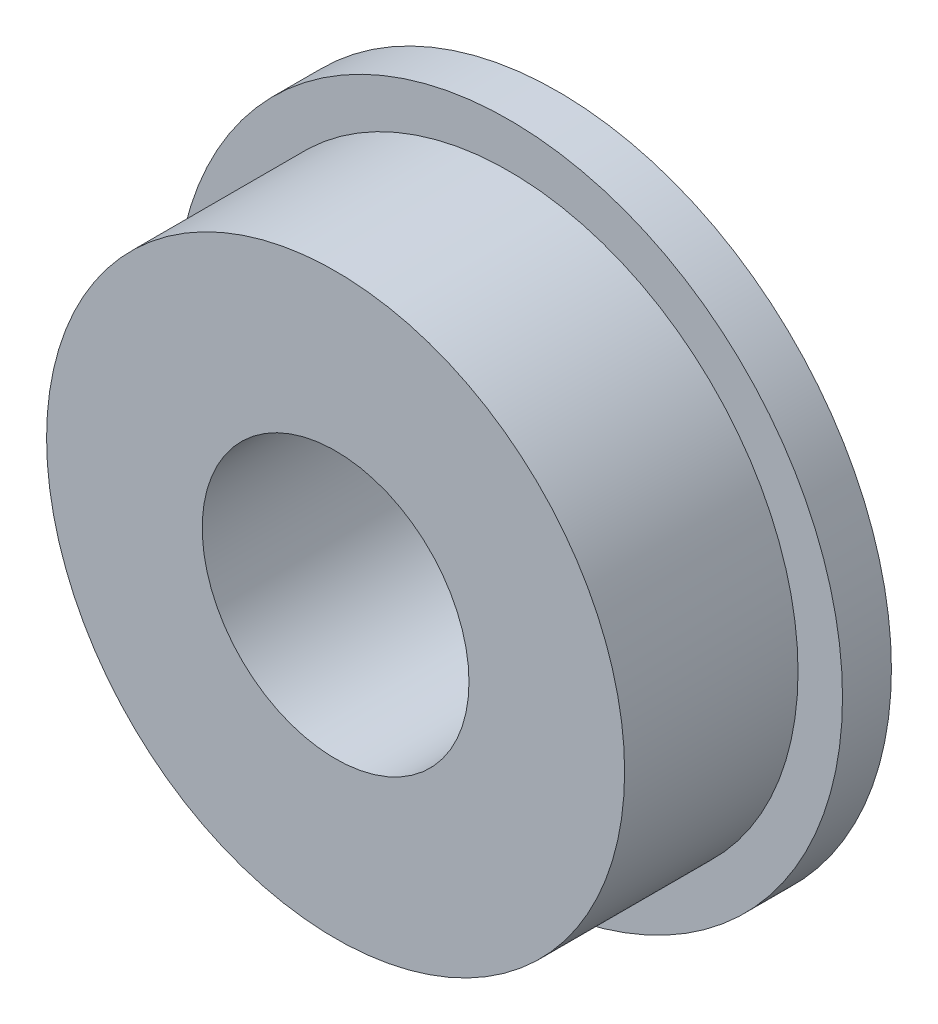
from build123d import *

# Parameters (mm, degrees)
SKETCH_1_R          = 7.5
SKETCH_1_R_2        = 3
EXTRUDE_1_DEPTH     = 5
SKETCH_2_R          = 7.5
SKETCH_2_R_2        = 6.5
CUT_EXTRUDE_1_DEPTH = 3.9
CHAMFER_1_SIZE      = 0.1
CHAMFER_1_SIZE2     = 0.119175359


with BuildPart() as part:
    # 草图1 → 凸台-拉伸1 (new body)
    with BuildSketch(Plane.XY):
        Circle(SKETCH_1_R)
        Circle(SKETCH_1_R_2, mode=Mode.SUBTRACT)
    extrude(amount=EXTRUDE_1_DEPTH)

    # 草图2 → 切除-拉伸1 (cut)
    with BuildSketch(Plane.XY.offset(5)):
        Circle(SKETCH_2_R)
        Circle(SKETCH_2_R_2, mode=Mode.SUBTRACT)
    extrude(amount=-CUT_EXTRUDE_1_DEPTH, mode=Mode.SUBTRACT)

    # 倒角1
    chamfer_1_edges = [part.edges().sort_by_distance(p)[0] for p in [
        (-3, 0, 0),
    ]]
    chamfer_1_side = [part.faces().sort_by_distance(p)[0] for p in [
        (-3, 0, 2.5),
    ]]
    chamfer(chamfer_1_edges, length=CHAMFER_1_SIZE, length2=CHAMFER_1_SIZE2, reference=chamfer_1_side[0])


solid = part.part
